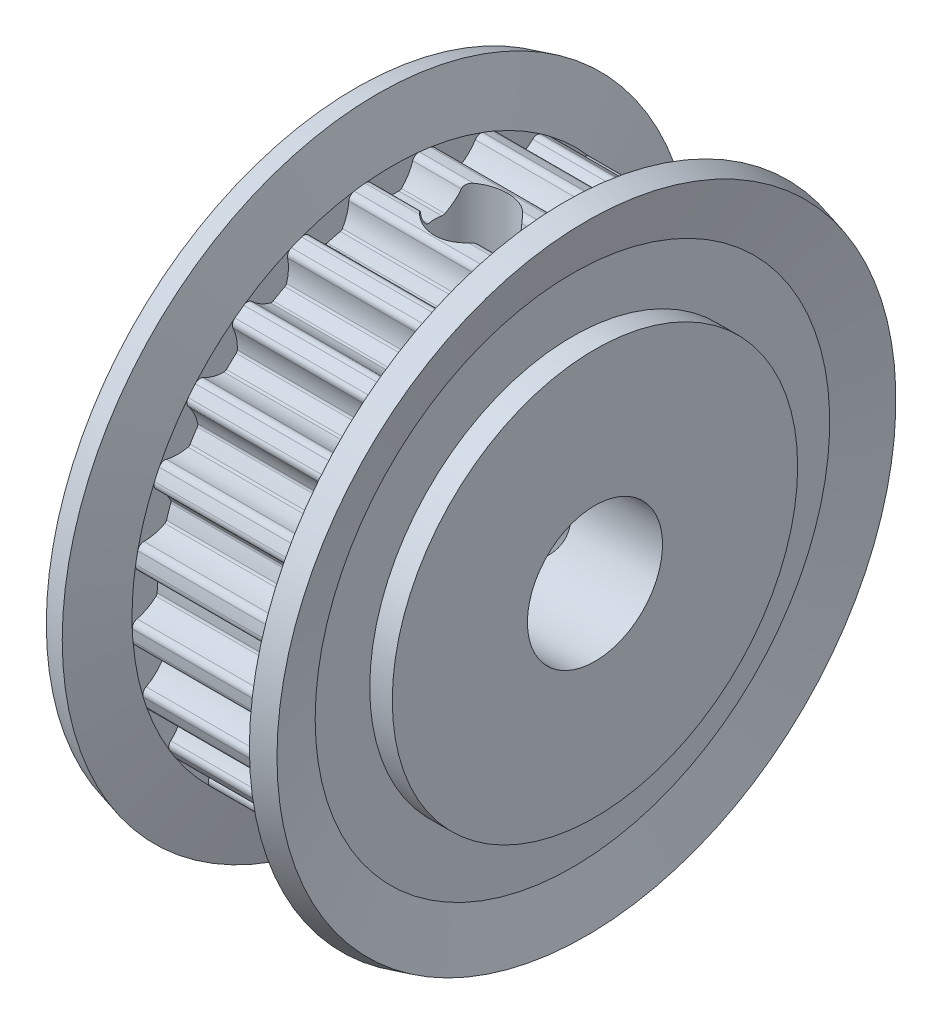
from build123d import *

# Parameters (mm, degrees)
SKETCH_2_W          = 11
SKETCH_2_H          = 3
SKETCH_3_R          = 16.555
CUT_EXTRUDE_1_DEPTH = 7
SKETCH_4_W          = 1.621
SKETCH_4_H          = 11.555


with BuildPart() as part:
    # ｽｹｯﾁ1 → 回転1 (revolve)
    with BuildSketch(Plane.XY):
        Polygon((0, 0), (0, 9), (1, 9), (1, 11.423347502), (0.378938398, 13.741180955), (1.344864225, 14), (2, 11.555), (9, 11.555), (9.655135775, 14), (10.621061602, 13.741180955), (10, 11.423347502), (10, 9), (11, 9), (11, 0), align=None)
    revolve(axis=Axis((11, 0, 0), (-1, 0, 0)))

    # ｽｹｯﾁ2 → ｶｯﾄ - 回転1 (revolve, cut)
    with BuildSketch(Plane.XY):
        with Locations((5.5, 1.5)):
            Rectangle(SKETCH_2_W, SKETCH_2_H)
    revolve(axis=Axis((11, 0, 0), (-1, 0, 0)), mode=Mode.SUBTRACT)

    # ｽｹｯﾁ3 → ｶｯﾄ - 押し出し1 (cut)
    with BuildSketch(Plane(origin=(2, 0, 0), x_dir=(0, 0, -1), z_dir=(1, 0, 0))):
        Circle(SKETCH_3_R)
        with BuildLine():
            ThreePointArc((-11.332966097, -0.196444366), (-11.489436939, -0.300352634), (-11.54503575, -0.479765077))
            ThreePointArc((-11.54503575, -0.479765077), (-11.532198847, -0.725544453), (-11.514130203, -0.970994676))
            ThreePointArc((-11.514130203, -0.970994676), (-11.436483502, -1.14202398), (-11.268223391, -1.22550193))
            ThreePointArc((-11.268223391, -1.22550193), (-10.800197727, -1.340439678), (-10.37394327, -1.565308189))
            ThreePointArc((-10.37394327, -1.565308189), (-10.33263186, -1.608574053), (-10.311513919, -1.66454369))
            ThreePointArc((-10.311513919, -1.66454369), (-10.259990339, -1.957197803), (-10.200162589, -2.248267811))
            ThreePointArc((-10.200162589, -2.248267811), (-10.199193738, -2.308081117), (-10.221676888, -2.363516468))
            ThreePointArc((-10.221676888, -2.363516468), (-10.535218601, -2.729508622), (-10.9280664, -3.008666765))
            ThreePointArc((-10.9280664, -3.008666765), (-11.053780488, -3.148223279), (-11.063014499, -3.335826013))
            ThreePointArc((-11.063014499, -3.335826013), (-10.989458046, -3.57069137), (-10.910916073, -3.803936834))
            ThreePointArc((-10.910916073, -3.803936834), (-10.793175527, -3.95028299), (-10.609441492, -3.989293737))
            ThreePointArc((-10.609441492, -3.989293737), (-10.127535861, -3.984227255), (-9.658750449, -4.096025935))
            ThreePointArc((-9.658750449, -4.096025935), (-9.607977129, -4.127658793), (-9.573603565, -4.176618222))
            ThreePointArc((-9.573603565, -4.176618222), (-9.450918575, -4.447264675), (-9.320584257, -4.714311627))
            ThreePointArc((-9.320584257, -4.714311627), (-9.304770879, -4.772004843), (-9.312761468, -4.831289921))
            ThreePointArc((-9.312761468, -4.831289921), (-9.525434144, -5.263758413), (-9.8365161, -5.631843566))
            ThreePointArc((-9.8365161, -5.631843566), (-9.923574355, -5.798279478), (-9.885863361, -5.982284732))
            ThreePointArc((-9.885863361, -5.982284732), (-9.756209179, -6.191478616), (-9.622128959, -6.397863651))
            ThreePointArc((-9.622128959, -6.397863651), (-9.471692637, -6.51033119), (-9.284029365, -6.502423544))
            ThreePointArc((-9.284029365, -6.502423544), (-8.81852367, -6.37767118), (-8.336662815, -6.369375308))
            ThreePointArc((-8.336662815, -6.369375308), (-8.279617858, -6.387387551), (-8.234148487, -6.426260476))
            ThreePointArc((-8.234148487, -6.426260476), (-8.048010837, -6.657893553), (-7.855359336, -6.884137905))
            ThreePointArc((-7.855359336, -6.884137905), (-7.825695045, -6.936085957), (-7.818690996, -6.995495666))
            ThreePointArc((-7.818690996, -6.995495666), (-7.917131629, -7.467266907), (-8.126901318, -7.901150923))
            ThreePointArc((-8.126901318, -7.901150923), (-8.169833549, -8.084008453), (-8.087547069, -8.2528545))
            ThreePointArc((-8.087547069, -8.2528545), (-7.909941809, -8.42323249), (-7.728748095, -8.589789164))
            ThreePointArc((-7.728748095, -8.589789164), (-7.555068458, -8.661311338), (-7.375267519, -8.606982156))
            ThreePointArc((-7.375267519, -8.606982156), (-6.955411198, -8.370382565), (-6.490751996, -8.242513405))
            ThreePointArc((-6.490751996, -8.242513405), (-6.431019749, -8.245773257), (-6.377311578, -8.272117144))
            ThreePointArc((-6.377311578, -8.272117144), (-6.139416981, -8.450182491), (-5.896553299, -8.621408481))
            ThreePointArc((-5.896553299, -8.621408481), (-5.854902011, -8.66434728), (-5.833343413, -8.720148687))
            ThreePointArc((-5.833343413, -8.720148687), (-5.811366615, -9.201579557), (-5.906643437, -9.67399991))
            ThreePointArc((-5.906643437, -9.67399991), (-5.902752055, -9.861789445), (-5.781060452, -10.004867068))
            ThreePointArc((-5.781060452, -10.004867068), (-5.566663704, -10.125723688), (-5.349741563, -10.241986634))
            ThreePointArc((-5.349741563, -10.241986634), (-5.16373155, -10.268069437), (-5.003090506, -10.170732431))
            ThreePointArc((-5.003090506, -10.170732431), (-4.65526467, -9.837152031), (-4.237003358, -9.597744071))
            ThreePointArc((-4.237003358, -9.597744071), (-4.178337017, -9.586046702), (-4.119764729, -9.598206269))
            ThreePointArc((-4.119764729, -9.598206269), (-3.845061072, -9.711515348), (-3.567245326, -9.816964184))
            ThreePointArc((-3.567245326, -9.816964184), (-3.516224022, -9.848195732), (-3.481465405, -9.896882708))
            ThreePointArc((-3.481465405, -9.896882708), (-3.340452064, -10.357723129), (-3.315249426, -10.838995903))
            ThreePointArc((-3.315249426, -10.838995903), (-3.264778941, -11.019917938), (-3.111328545, -11.128237043))
            ThreePointArc((-3.111328545, -11.128237043), (-2.873611646, -11.191978427), (-2.634591094, -11.250642416))
            ThreePointArc((-2.634591094, -11.250642416), (-2.447938398, -11.229646971), (-2.316550917, -11.095418183))
            ThreePointArc((-2.316550917, -11.095418183), (-2.062610741, -10.685817056), (-1.717028216, -10.349913179))
            ThreePointArc((-1.717028216, -10.349913179), (-1.663114003, -10.323993579), (-1.60335791, -10.321204795))
            ThreePointArc((-1.60335791, -10.321204795), (-1.30910565, -10.362638052), (-1.013793834, -10.395684059))
            ThreePointArc((-1.013793834, -10.395684059), (-0.956608602, -10.413245958), (-0.910834123, -10.451759177))
            ThreePointArc((-0.910834123, -10.451759177), (-0.659644623, -10.863052857), (-0.515546101, -11.322937921))
            ThreePointArc((-0.515546101, -11.322937921), (-0.421667758, -11.485624458), (-0.246100423, -11.552378958))
            ThreePointArc((-0.246100423, -11.552378958), (0, -11.555), (0.246100423, -11.552378958))
            ThreePointArc((0.246100423, -11.552378958), (0.421667726, -11.485624485), (0.515546086, -11.322938004))
            ThreePointArc((0.515546086, -11.322938004), (0.659644606, -10.863052896), (0.910834123, -10.451759177))
            ThreePointArc((0.910834123, -10.451759177), (0.95660858, -10.41324597), (1.013793783, -10.395684064))
            ThreePointArc((1.013793783, -10.395684064), (1.309105599, -10.362638058), (1.60335786, -10.321204802))
            ThreePointArc((1.60335786, -10.321204802), (1.66311397, -10.323993571), (1.717028202, -10.349913168))
            ThreePointArc((1.717028202, -10.349913168), (2.062610709, -10.685817016), (2.316550882, -11.095418106))
            ThreePointArc((2.316550882, -11.095418106), (2.44793836, -11.229646952), (2.634591094, -11.250642416))
            ThreePointArc((2.634591094, -11.250642416), (2.873611646, -11.191978427), (3.111328545, -11.128237043))
            ThreePointArc((3.111328545, -11.128237043), (3.264778916, -11.019917972), (3.315249432, -10.838995987))
            ThreePointArc((3.315249432, -10.838995987), (3.340452057, -10.357723171), (3.481465405, -9.896882708))
            ThreePointArc((3.481465405, -9.896882708), (3.516223929, -9.848195818), (3.567245088, -9.81696427))
            ThreePointArc((3.567245088, -9.81696427), (3.845060835, -9.711515442), (4.119764492, -9.59820637))
            ThreePointArc((4.119764492, -9.59820637), (4.178336874, -9.586046703), (4.237003331, -9.597744059))
            ThreePointArc((4.237003331, -9.597744059), (4.655264629, -9.837152), (5.00309046, -10.170732375))
            ThreePointArc((5.00309046, -10.170732375), (5.163731514, -10.26806943), (5.349741563, -10.241986634))
            ThreePointArc((5.349741563, -10.241986634), (5.566663704, -10.125723688), (5.781060452, -10.004867068))
            ThreePointArc((5.781060452, -10.004867068), (5.90275204, -9.861789485), (5.906643464, -9.67399999))
            ThreePointArc((5.906643464, -9.67399999), (5.811366619, -9.201579606), (5.833343411, -8.7201487))
            ThreePointArc((5.833343411, -8.7201487), (5.854901995, -8.664347305), (5.89655326, -8.621408507))
            ThreePointArc((5.89655326, -8.621408507), (6.139416941, -8.45018252), (6.377311538, -8.272117175))
            ThreePointArc((6.377311538, -8.272117175), (6.431019712, -8.245773266), (6.490751972, -8.242513401))
            ThreePointArc((6.490751972, -8.242513401), (6.955411148, -8.370382544), (7.375267451, -8.606982106))
            ThreePointArc((7.375267451, -8.606982106), (7.555068416, -8.66131134), (7.728748095, -8.589789164))
            ThreePointArc((7.728748095, -8.589789164), (7.909941809, -8.42323249), (8.087547069, -8.2528545))
            ThreePointArc((8.087547069, -8.2528545), (8.169833545, -8.084008495), (8.126901364, -7.901150994))
            ThreePointArc((8.126901364, -7.901150994), (7.917131644, -7.467266953), (7.818690997, -6.995495679))
            ThreePointArc((7.818690997, -6.995495679), (7.825695037, -6.936085982), (7.85535931, -6.884137935))
            ThreePointArc((7.85535931, -6.884137935), (8.048010808, -6.657893588), (8.234148455, -6.426260516))
            ThreePointArc((8.234148455, -6.426260516), (8.279617826, -6.387387569), (8.336662792, -6.36937531))
            ThreePointArc((8.336662792, -6.36937531), (8.818523613, -6.377671172), (9.284029281, -6.50242351))
            ThreePointArc((9.284029281, -6.50242351), (9.471692594, -6.510331203), (9.622128959, -6.397863651))
            ThreePointArc((9.622128959, -6.397863651), (9.756209179, -6.191478616), (9.885863361, -5.982284732))
            ThreePointArc((9.885863361, -5.982284732), (9.923574361, -5.79827952), (9.836516162, -5.631843623))
            ThreePointArc((9.836516162, -5.631843623), (9.525434171, -5.263758455), (9.312761473, -4.831289936))
            ThreePointArc((9.312761473, -4.831289936), (9.304770878, -4.772004866), (9.320584242, -4.714311655))
            ThreePointArc((9.320584242, -4.714311655), (9.450918556, -4.447264715), (9.573603543, -4.176618274))
            ThreePointArc((9.573603543, -4.176618274), (9.607977117, -4.127658805), (9.65875047, -4.096025927))
            ThreePointArc((9.65875047, -4.096025927), (10.127535824, -3.984227259), (10.609441398, -3.989293724))
            ThreePointArc((10.609441398, -3.989293724), (10.793175486, -3.950283015), (10.910916073, -3.803936834))
            ThreePointArc((10.910916073, -3.803936834), (10.989458046, -3.57069137), (11.063014499, -3.335826013))
            ThreePointArc((11.063014499, -3.335826013), (11.053780504, -3.148223318), (10.928066474, -3.008666805))
            ThreePointArc((10.928066474, -3.008666805), (10.535218637, -2.729508655), (10.221676895, -2.363516479))
            ThreePointArc((10.221676895, -2.363516479), (10.199193735, -2.308081103), (10.200162598, -2.248267772))
            ThreePointArc((10.200162598, -2.248267772), (10.259990338, -1.957197811), (10.31151391, -1.664543746))
            ThreePointArc((10.31151391, -1.664543746), (10.33263185, -1.608574068), (10.373943288, -1.565308176))
            ThreePointArc((10.373943288, -1.565308176), (10.800197691, -1.340439692), (11.268223293, -1.225501942))
            ThreePointArc((11.268223293, -1.225501942), (11.436483468, -1.142024016), (11.514130203, -0.970994676))
            ThreePointArc((11.514130203, -0.970994676), (11.532198847, -0.725544453), (11.54503575, -0.479765077))
            ThreePointArc((11.54503575, -0.479765077), (11.489436964, -0.300352667), (11.332966179, -0.196444387))
            ThreePointArc((11.332966179, -0.196444387), (10.88303657, -0.023753787), (10.488326766, 0.252765411))
            ThreePointArc((10.488326766, 0.252765411), (10.45276374, 0.300867844), (10.438827192, 0.359042972))
            ThreePointArc((10.438827192, 0.359042972), (10.424389177, 0.655846992), (10.401513935, 0.952120187))
            ThreePointArc((10.401513935, 0.952120187), (10.408049324, 1.011583293), (10.437303097, 1.063763644))
            ThreePointArc((10.437303097, 1.063763644), (10.794243416, 1.387572631), (11.218981277, 1.615292635))
            ThreePointArc((11.218981277, 1.615292635), (11.361195133, 1.737992552), (11.393869186, 1.922958648))
            ThreePointArc((11.393869186, 1.922958648), (11.350329182, 2.16519109), (11.301639945, 2.406441263))
            ThreePointArc((11.301639945, 2.406441263), (11.203169846, 2.566390246), (11.025773939, 2.628121355))
            ThreePointArc((11.025773939, 2.628121355), (10.54703329, 2.683493619), (10.095956492, 2.853165121))
            ThreePointArc((10.095956492, 2.853165121), (10.049548156, 2.890912163), (10.021581884, 2.943793733))
            ThreePointArc((10.021581884, 2.943793733), (9.933785308, 3.227682521), (9.837948586, 3.508958908))
            ThreePointArc((9.837948586, 3.508958908), (9.82949078, 3.56817915), (9.844848761, 3.625995272))
            ThreePointArc((9.844848761, 3.625995272), (10.110047125, 4.028398657), (10.464809407, 4.354592434))
            ThreePointArc((10.464809407, 4.354592434), (10.572041125, 4.508804656), (10.557689465, 4.696085408))
            ThreePointArc((10.557689465, 4.696085408), (10.455276591, 4.919879714), (10.348120538, 5.141442049))
            ThreePointArc((10.348120538, 5.141442049), (10.212966363, 5.271877422), (10.025791772, 5.287552567))
            ThreePointArc((10.025791772, 5.287552567), (9.548321119, 5.222127251), (9.069220142, 5.274289973))
            ThreePointArc((9.069220142, 5.274289973), (9.014882501, 5.299309838), (8.974643729, 5.343575108))
            ThreePointArc((8.974643729, 5.343575108), (8.819005173, 5.596710887), (8.656228746, 5.845316835))
            ThreePointArc((8.656228746, 5.845316835), (8.633309183, 5.900573189), (8.633806377, 5.960392281))
            ThreePointArc((8.633806377, 5.960392281), (8.790599394, 6.41610558), (9.053095075, 6.820277176))
            ThreePointArc((9.053095075, 6.820277176), (9.118606891, 6.996311981), (9.058131286, 7.174139852))
            ThreePointArc((9.058131286, 7.174139852), (8.90328052, 7.365434202), (8.744390659, 7.553387121))
            ThreePointArc((8.744390659, 7.553387121), (8.581044643, 7.646113151), (8.395852236, 7.614747404))
            ThreePointArc((8.395852236, 7.614747404), (7.949652816, 7.432635422), (7.472631336, 7.364011789))
            ThreePointArc((7.472631336, 7.364011789), (7.413778624, 7.374732387), (7.363795703, 7.407600006))
            ThreePointArc((7.363795703, 7.407600006), (7.15009451, 7.614077324), (6.930606218, 7.814392008))
            ThreePointArc((6.930606218, 7.814392008), (6.89466502, 7.862212515), (6.88027019, 7.920275923))
            ThreePointArc((6.88027019, 7.920275923), (6.918805975, 8.400664993), (7.072541484, 8.85741882))
            ThreePointArc((7.072541484, 8.85741882), (7.092217051, 9.044215293), (6.989417404, 9.201416703))
            ThreePointArc((6.989417404, 9.201416703), (6.79185859, 9.34819137), (6.591218556, 9.490725101))
            ThreePointArc((6.591218556, 9.490725101), (6.409944329, 9.53991547), (6.238370427, 9.463479657))
            ThreePointArc((6.238370427, 9.463479657), (5.85147859, 9.176123775), (5.40650962, 8.99102566))
            ThreePointArc((5.40650962, 8.99102566), (5.346839771, 8.986773377), (5.29025331, 9.006178152))
            ThreePointArc((5.29025331, 9.006178152), (5.031917022, 9.15302333), (4.769508029, 9.292460286))
            ThreePointArc((4.769508029, 9.292460286), (4.722803629, 9.329840199), (4.694421322, 9.382499515))
            ThreePointArc((4.694421322, 9.382499515), (4.612278534, 9.857379735), (4.647594101, 10.338016263))
            ThreePointArc((4.647594101, 10.338016263), (4.62019713, 10.523837297), (4.481532722, 10.650534703))
            ThreePointArc((4.481532722, 10.650534703), (4.253679206, 10.743567294), (4.02389595, 10.831725919))
            ThreePointArc((4.02389595, 10.831725919), (3.836083637, 10.834289814), (3.688908857, 10.717586675))
            ThreePointArc((3.688908857, 10.717586675), (3.385634442, 10.343042521), (3.000677022, 10.053100323))
            ThreePointArc((3.000677022, 10.053100323), (2.94393931, 10.034142345), (2.884304846, 10.038865003))
            ThreePointArc((2.884304846, 10.038865003), (2.597565856, 10.116851122), (2.308724465, 10.186648926))
            ThreePointArc((2.308724465, 10.186648926), (2.254191242, 10.211239556), (2.213604694, 10.255186155))
            ThreePointArc((2.213604694, 10.255186155), (2.015944667, 10.694719056), (1.930621288, 11.169038125))
            ThreePointArc((1.930621288, 11.169038125), (1.857873231, 11.342207899), (1.692056857, 11.430440437))
            ThreePointArc((1.692056857, 11.430440437), (1.448225514, 11.463885374), (1.203737163, 11.492129561))
            ThreePointArc((1.203737163, 11.492129561), (1.021187706, 11.447905885), (0.907659583, 11.298268314))
            ThreePointArc((0.907659583, 11.298268314), (0.707058434, 10.86006987), (0.40630085, 10.48350172))
            ThreePointArc((0.40630085, 10.48350172), (0.356060319, 10.451029248), (0.297124907, 10.440773046))
            ThreePointArc((0.297124907, 10.440773046), (-1.2e-08, 10.445), (-0.297124932, 10.440773045))
            ThreePointArc((-0.297124932, 10.440773045), (-0.35606033, 10.451029253), (-0.40630085, 10.48350172))
            ThreePointArc((-0.40630085, 10.48350172), (-0.707058415, 10.860069839), (-0.907659561, 11.298268244))
            ThreePointArc((-0.907659561, 11.298268244), (-1.021187685, 11.447905872), (-1.203737186, 11.492129558))
            ThreePointArc((-1.203737186, 11.492129558), (-1.448225526, 11.463885372), (-1.692056857, 11.430440437))
            ThreePointArc((-1.692056857, 11.430440437), (-1.857873219, 11.342207912), (-1.930621286, 11.169038161))
            ThreePointArc((-1.930621286, 11.169038161), (-2.015944663, 10.69471907), (-2.213604698, 10.255186148))
            ThreePointArc((-2.213604698, 10.255186148), (-2.254191272, 10.211239535), (-2.308724528, 10.186648912))
            ThreePointArc((-2.308724528, 10.186648912), (-2.597565903, 10.11685111), (-2.884304876, 10.038864995))
            ThreePointArc((-2.884304876, 10.038864995), (-2.943939311, 10.034142345), (-3.000676996, 10.053100308))
            ThreePointArc((-3.000676996, 10.053100308), (-3.385634407, 10.343042487), (-3.688908821, 10.717586617))
            ThreePointArc((-3.688908821, 10.717586617), (-3.836083605, 10.834289803), (-4.02389595, 10.831725919))
            ThreePointArc((-4.02389595, 10.831725919), (-4.253679206, 10.743567294), (-4.481532722, 10.650534703))
            ThreePointArc((-4.481532722, 10.650534703), (-4.62019712, 10.523837314), (-4.647594109, 10.338016301))
            ThreePointArc((-4.647594109, 10.338016301), (-4.612278533, 9.857379755), (-4.694421322, 9.382499515))
            ThreePointArc((-4.694421322, 9.382499515), (-4.722803674, 9.329840144), (-4.769508155, 9.292460221))
            ThreePointArc((-4.769508155, 9.292460221), (-5.031917098, 9.153023289), (-5.290253337, 9.006178136))
            ThreePointArc((-5.290253337, 9.006178136), (-5.346839772, 8.986773377), (-5.406509592, 8.991025653))
            ThreePointArc((-5.406509592, 8.991025653), (-5.851478546, 9.176123749), (-6.238370374, 9.463479607))
            ThreePointArc((-6.238370374, 9.463479607), (-6.409944293, 9.539915467), (-6.591218556, 9.490725101))
            ThreePointArc((-6.591218556, 9.490725101), (-6.79185859, 9.34819137), (-6.989417404, 9.201416703))
            ThreePointArc((-6.989417404, 9.201416703), (-7.092217046, 9.044215314), (-7.072541503, 8.857418858))
            ThreePointArc((-7.072541503, 8.857418858), (-6.91880598, 8.400665017), (-6.88027019, 7.920275931))
            ThreePointArc((-6.88027019, 7.920275931), (-6.894665005, 7.862212547), (-6.930606169, 7.814392051))
            ThreePointArc((-6.930606169, 7.814392051), (-7.150094498, 7.614077336), (-7.363795725, 7.407599984))
            ThreePointArc((-7.363795725, 7.407599984), (-7.41377863, 7.374732385), (-7.472631315, 7.364011788))
            ThreePointArc((-7.472631315, 7.364011788), (-7.949652766, 7.432635408), (-8.395852163, 7.614747363))
            ThreePointArc((-8.395852163, 7.614747363), (-8.581044602, 7.646113158), (-8.744390659, 7.553387121))
            ThreePointArc((-8.744390659, 7.553387121), (-8.90328052, 7.365434202), (-9.058131286, 7.174139852))
            ThreePointArc((-9.058131286, 7.174139852), (-9.118606891, 6.996312004), (-9.053095105, 6.820277212))
            ThreePointArc((-9.053095105, 6.820277212), (-8.790599404, 6.416105601), (-8.633806377, 5.960392281))
            ThreePointArc((-8.633806377, 5.960392281), (-8.633309177, 5.900573218), (-8.656228712, 5.845316885))
            ThreePointArc((-8.656228712, 5.845316885), (-8.819005166, 5.596710899), (-8.974643746, 5.34357508))
            ThreePointArc((-8.974643746, 5.34357508), (-9.014882506, 5.299309835), (-9.069220122, 5.274289978))
            ThreePointArc((-9.069220122, 5.274289978), (-9.548321067, 5.22212725), (-10.025791691, 5.287552545))
            ThreePointArc((-10.025791691, 5.287552545), (-10.212966325, 5.27187744), (-10.348120538, 5.141442049))
            ThreePointArc((-10.348120538, 5.141442049), (-10.455276591, 4.919879714), (-10.557689465, 4.696085408))
            ThreePointArc((-10.557689465, 4.696085408), (-10.572041131, 4.508804678), (-10.464809445, 4.354592461))
            ThreePointArc((-10.464809445, 4.354592461), (-10.110047137, 4.028398672), (-9.844848757, 3.625995263))
            ThreePointArc((-9.844848757, 3.625995263), (-9.829490781, 3.568179175), (-9.837948566, 3.508958964))
            ThreePointArc((-9.837948566, 3.508958964), (-9.933785303, 3.227682535), (-10.021581893, 2.943793703))
            ThreePointArc((-10.021581893, 2.943793703), (-10.049548161, 2.890912157), (-10.095956478, 2.853165128))
            ThreePointArc((-10.095956478, 2.853165128), (-10.547033241, 2.68349363), (-11.025773854, 2.628121355))
            ThreePointArc((-11.025773854, 2.628121355), (-11.203169813, 2.566390273), (-11.301639945, 2.406441263))
            ThreePointArc((-11.301639945, 2.406441263), (-11.350329182, 2.16519109), (-11.393869186, 1.922958648))
            ThreePointArc((-11.393869186, 1.922958648), (-11.361195144, 1.73799257), (-11.218981317, 1.61529265))
            ThreePointArc((-11.218981317, 1.61529265), (-10.794243425, 1.387572637), (-10.437303083, 1.063763628))
            ThreePointArc((-10.437303083, 1.063763628), (-10.40804933, 1.011583311), (-10.40151393, 0.952120247))
            ThreePointArc((-10.40151393, 0.952120247), (-10.424389177, 0.655847006), (-10.438827193, 0.35904294))
            ThreePointArc((-10.438827193, 0.35904294), (-10.452763745, 0.300867833), (-10.48832676, 0.252765416))
            ThreePointArc((-10.48832676, 0.252765416), (-10.883036529, -0.023753765), (-11.332966097, -0.196444366))
        make_face(mode=Mode.SUBTRACT)
    extrude(amount=CUT_EXTRUDE_1_DEPTH, mode=Mode.SUBTRACT)

    # ｽｹｯﾁ4 → ｶｯﾄ - 回転2 (revolve, cut)
    with BuildSketch(Plane(origin=(5.5, 0, 0), x_dir=(0, 0, -1), z_dir=(1, 0, 0))):
        with Locations((0.8105, 5.7775)):
            Rectangle(SKETCH_4_W, SKETCH_4_H)
    revolve(axis=Axis((5.5, 0, 0), (0, 1, 0)), mode=Mode.SUBTRACT)

    # ｽｹｯﾁ5 → ｶｯﾄ - 回転3 (revolve, cut)
    with BuildSketch(Plane(origin=(5.5, 0, 0), x_dir=(0, 0, -1), z_dir=(1, 0, 0))):
        Polygon((10.455276591, -4.919879714), (9.76508836, -6.386604366), (-0.690188232, -1.466724652), (0, 0), align=None)
    revolve(axis=Axis((5.5, 0, 0), (0, -0.425779292, -0.904827052)), mode=Mode.SUBTRACT)


solid = part.part
